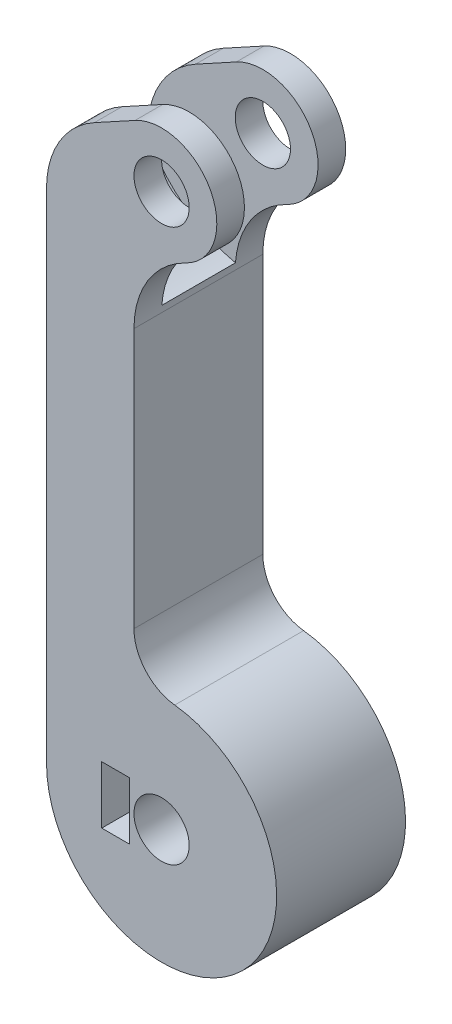
from build123d import *

# Parameters (mm, degrees)
CROQUIS1_R              = 3
SALIENTE_EXTRUIR1_DEPTH = 14
REDONDEO1_R             = 10
REDONDEO2_R             = 10
REDONDEO3_R             = 5
CORTAR_EXTRUIR1_START   = -3
CROQUIS2_R              = 14
CORTAR_EXTRUIR1_DEPTH   = 8
CROQUIS3_R              = 1.5
CORTAR_EXTRUIR2_DEPTH   = 10
CROQUIS4_R              = 5
CORTAR_EXTRUIR3_DEPTH   = 3
CORTAR_EXTRUIR4_START   = -3
CROQUIS5_R              = 1.5
CORTAR_EXTRUIR4_DEPTH   = 3


with BuildPart() as part:
    # Croquis1 → Saliente-Extruir1 (new body)
    with BuildSketch(Plane.XY):
        with BuildLine():
            ThreePointArc((-12.5, 0), (9.842509843, -7.705517504), (-3, 12.1346611))
            Line((-3, 12.1346611), (-3, 54.803847577))
            ThreePointArc((-3, 54.803847577), (5.999605182, 59.93116932), (-2.88, 65.263610928))
            Line((-2.88, 65.263610928), (-12.5, 60))
            Line((-12.5, 60), (-12.5, 0))
        make_face()
        Circle(CROQUIS1_R, mode=Mode.SUBTRACT)
        with Locations((0, 60)):
            Circle(CROQUIS1_R, mode=Mode.SUBTRACT)
    extrude(amount=SALIENTE_EXTRUIR1_DEPTH)

    # Redondeo1
    redondeo1_edges = [part.edges().sort_by_distance(p)[0] for p in [
        (-12.5, 60, 7),
    ]]
    fillet(redondeo1_edges, radius=REDONDEO1_R)

    # Redondeo2
    redondeo2_edges = [part.edges().sort_by_distance(p)[0] for p in [
        (-3, 54.803847577, 7),
    ]]
    fillet(redondeo2_edges, radius=REDONDEO2_R)

    # Redondeo3
    redondeo3_edges = [part.edges().sort_by_distance(p)[0] for p in [
        (-3, 12.1346611, 7),
    ]]
    fillet(redondeo3_edges, radius=REDONDEO3_R)

    # Croquis2 → Cortar-Extruir1 (cut)
    with BuildSketch(Plane.XY.offset(14).offset(CORTAR_EXTRUIR1_START)):
        with Locations((0, 60)):
            Circle(CROQUIS2_R)
    extrude(amount=-CORTAR_EXTRUIR1_DEPTH, mode=Mode.SUBTRACT)

    # Croquis3 → Cortar-Extruir2 (cut)
    with BuildSketch(Plane.ZY.offset(12.5)):
        with Locations((7, 0)):
            Circle(CROQUIS3_R)
    extrude(amount=-CORTAR_EXTRUIR2_DEPTH, mode=Mode.SUBTRACT)

    # Croquis4 → Cortar-Extruir3 (cut)
    with BuildSketch(Plane.ZY.offset(12.5)):
        with Locations((7, 0)):
            Circle(CROQUIS4_R)
    extrude(amount=-CORTAR_EXTRUIR3_DEPTH, mode=Mode.SUBTRACT)

    # Croquis5 → Cortar-Extruir4 (cut)
    with BuildSketch(Plane.ZY.offset(9.5).offset(CORTAR_EXTRUIR4_START)):
        Polygon((8.804219591, 3.125), (8.804219591, -3.125), (5.195780409, -3.125), (3.391560818, 0), (5.195780409, 3.125), align=None)
        with Locations((7, 0)):
            Circle(CROQUIS5_R, mode=Mode.SUBTRACT)
        Polygon((10.608439182, 0), (8.804219591, 3.125), (8.804219591, -3.125), align=None)
        with BuildLine():
            Line((8.804219591, 3.125), (10.608439182, 0))
            Line((10.608439182, 0), (8.804219591, -3.125))
            Line((8.804219591, -3.125), (10.903123749, -3.125))
            ThreePointArc((10.903123749, -3.125), (11.717818285, -1.655956107), (12, 0))
            ThreePointArc((12, 0), (11.717818285, 1.655956107), (10.903123749, 3.125))
            Line((10.903123749, 3.125), (8.804219591, 3.125))
        make_face()
        with BuildLine():
            Line((14, 3.125), (10.903123749, 3.125))
            ThreePointArc((10.903123749, 3.125), (11.717818285, 1.655956107), (12, 0))
            ThreePointArc((12, 0), (11.717818285, -1.655956107), (10.903123749, -3.125))
            Line((10.903123749, -3.125), (14, -3.125))
            Line((14, -3.125), (14, 3.125))
        make_face()
    extrude(amount=-CORTAR_EXTRUIR4_DEPTH, mode=Mode.SUBTRACT)


solid = part.part
